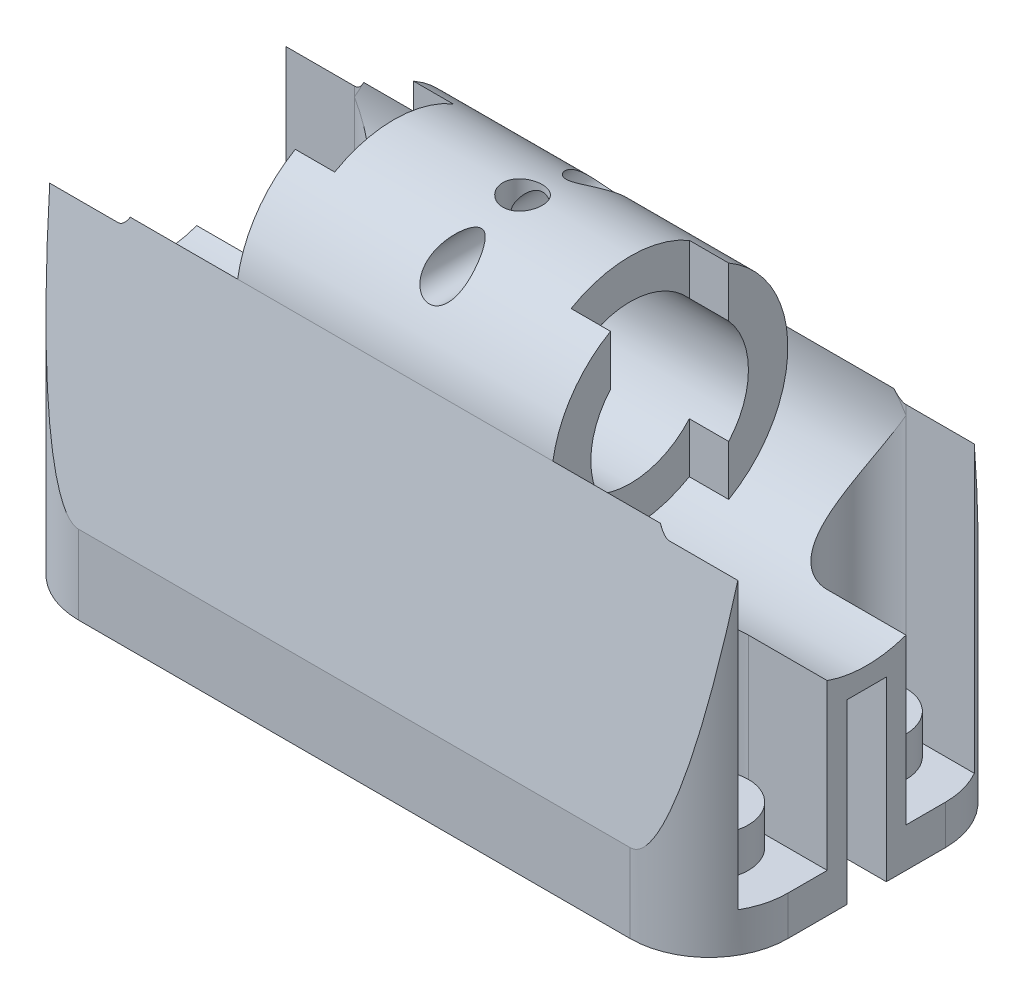
from build123d import *

# Parameters (mm, degrees)
BOSS_EXTRUDE3_DEPTH      = 110
CUT_EXTRUDE3_DEPTH       = 90
CUT_EXTRUDE4_DEPTH       = 10
CUT_EXTRUDE5_DEPTH       = 90
CUT_EXTRUDE6_DEPTH       = 10
CUT_EXTRUDE7_DEPTH       = 10
CUT_EXTRUDE8_DEPTH       = 10
CUT_EXTRUDE11_DEPTH      = 159
CUT_EXTRUDE11_DEPTH_BACK = 165
SKETCH11_R               = 30
CUT_EXTRUDE12_DEPTH      = 165
SKETCH12_R               = 30
CUT_EXTRUDE13_DEPTH      = 165
CUT_EXTRUDE14_DEPTH      = 10
CUT_EXTRUDE15_DEPTH      = 10
SKETCH15_R               = 20
CUT_EXTRUDE16_DEPTH      = 91
SKETCH16_R               = 5
CUT_EXTRUDE17_DEPTH      = 157
SKETCH17_W               = 10
SKETCH17_H               = 45
CUT_EXTRUDE20_DEPTH      = 157
CUT_EXTRUDE20_DEPTH_BACK = 157
SKETCH19_R               = 5
CUT_EXTRUDE23_DEPTH      = 157


with BuildPart() as part:
    # Sketch1 → Boss-Extrude3 (new body)
    with BuildSketch(Plane(origin=(0, 0, 0), x_dir=(1, 0, 0), z_dir=(0, 1, 0))):
        with BuildLine():
            Line((20, 0), (160, 0))
            ThreePointArc((160, 0), (174.142135624, 5.857864376), (180, 20))
            Line((180, 20), (180, 60))
            ThreePointArc((180, 60), (174.142135624, 74.142135624), (160, 80))
            Line((160, 80), (20, 80))
            ThreePointArc((20, 80), (5.857864376, 74.142135624), (0, 60))
            Line((0, 60), (0, 20))
            ThreePointArc((0, 20), (5.857864376, 5.857864376), (20, 0))
        make_face()
    extrude(amount=BOSS_EXTRUDE3_DEPTH)

    # Sketch4 → Cut-Extrude3 (cut)
    with BuildSketch(Plane(origin=(0, 110, 0), x_dir=(1, 0, 0), z_dir=(0, 1, 0))):
        with BuildLine():
            Line((0, 50), (20, 50))
            ThreePointArc((20, 50), (30, 60), (20, 70))
            Line((20, 70), (2.679491924, 70))
            ThreePointArc((2.679491924, 70), (0.681483474, 65.176380902), (0, 60))
            Line((0, 60), (0, 50))
        make_face()
    extrude(amount=-CUT_EXTRUDE3_DEPTH, mode=Mode.SUBTRACT)

    # Sketch5 → Cut-Extrude4 (cut)
    with BuildSketch(Plane(origin=(0, 20, 0), x_dir=(1, 0, 0), z_dir=(0, 1, 0))):
        with BuildLine():
            Line((0, 50), (20, 50))
            ThreePointArc((20, 50), (10, 60), (20, 70))
            Line((20, 70), (2.679491924, 70))
            ThreePointArc((2.679491924, 70), (0.681483474, 65.176380902), (0, 60))
            Line((0, 60), (0, 50))
        make_face()
    extrude(amount=-CUT_EXTRUDE4_DEPTH, mode=Mode.SUBTRACT)

    # Sketch6 → Cut-Extrude5 (cut)
    with BuildSketch(Plane(origin=(0, 110, 0), x_dir=(1, 0, 0), z_dir=(0, 1, 0))):
        with BuildLine():
            Line((2.679491924, 10), (20, 10))
            ThreePointArc((20, 10), (30, 20), (20, 30))
            Line((20, 30), (0, 30))
            Line((0, 30), (0, 20))
            ThreePointArc((0, 20), (0.681483474, 14.823619098), (2.679491924, 10))
        make_face()
        with BuildLine():
            Line((177.320508076, 70), (160, 70))
            ThreePointArc((160, 70), (150, 60), (160, 50))
            Line((160, 50), (180, 50))
            Line((180, 50), (180, 60))
            ThreePointArc((180, 60), (179.318516526, 65.176380902), (177.320508076, 70))
        make_face()
        with BuildLine():
            Line((180, 30), (160, 30))
            ThreePointArc((160, 30), (150, 20), (160, 10))
            Line((160, 10), (177.320508076, 10))
            ThreePointArc((177.320508076, 10), (179.318516526, 14.823619098), (180, 20))
            Line((180, 20), (180, 30))
        make_face()
    extrude(amount=-CUT_EXTRUDE5_DEPTH, mode=Mode.SUBTRACT)

    # Sketch7 → Cut-Extrude6 (cut)
    with BuildSketch(Plane(origin=(0, 20, 0), x_dir=(1, 0, 0), z_dir=(0, 1, 0))):
        with BuildLine():
            Line((2.679491924, 10), (20, 10))
            ThreePointArc((20, 10), (10, 20), (20, 30))
            Line((20, 30), (0, 30))
            Line((0, 30), (0, 20))
            ThreePointArc((0, 20), (0.681483474, 14.823619098), (2.679491924, 10))
        make_face()
    extrude(amount=-CUT_EXTRUDE6_DEPTH, mode=Mode.SUBTRACT)

    # Sketch8 → Cut-Extrude7 (cut)
    with BuildSketch(Plane(origin=(0, 20, 0), x_dir=(1, 0, 0), z_dir=(0, 1, 0))):
        with BuildLine():
            ThreePointArc((170, 60), (167.071067812, 52.928932188), (160, 50))
            Line((160, 50), (180, 50))
            Line((180, 50), (180, 60))
            ThreePointArc((180, 60), (179.318516526, 65.176380902), (177.320508076, 70))
            Line((177.320508076, 70), (160, 70))
            ThreePointArc((160, 70), (167.071067812, 67.071067812), (170, 60))
        make_face()
    extrude(amount=-CUT_EXTRUDE7_DEPTH, mode=Mode.SUBTRACT)

    # Sketch9 → Cut-Extrude8 (cut)
    with BuildSketch(Plane(origin=(0, 20, 0), x_dir=(1, 0, 0), z_dir=(0, 1, 0))):
        with BuildLine():
            Line((180, 30), (160, 30))
            ThreePointArc((160, 30), (167.071067812, 27.071067812), (170, 20))
            ThreePointArc((170, 20), (167.071067812, 12.928932188), (160, 10))
            Line((160, 10), (177.320508076, 10))
            ThreePointArc((177.320508076, 10), (179.318516526, 14.823619098), (180, 20))
            Line((180, 20), (180, 30))
        make_face()
    extrude(amount=-CUT_EXTRUDE8_DEPTH, mode=Mode.SUBTRACT)

    # Sketch10 → Cut-Extrude11 (cut, two sides)
    with BuildSketch(Plane(origin=(50, 0, 0), x_dir=(0, 0, -1), z_dir=(1, 0, 0))) as cut_extrude11_sk:
        with BuildLine():
            Line((69.621902584, 84.747935056), (80, 20))
            Line((80, 20), (80, 110))
            Line((80, 110), (40, 110))
            ThreePointArc((40, 110), (59.46229622, 102.830221765), (69.621902584, 84.747935056))
        make_face()
        with BuildLine():
            ThreePointArc((10.378097416, 84.747935056), (20.53770378, 102.830221765), (40, 110))
            Line((40, 110), (0, 110))
            Line((0, 110), (0, 20))
            Line((0, 20), (10.378097416, 84.747935056))
        make_face()
    extrude(amount=CUT_EXTRUDE11_DEPTH, mode=Mode.SUBTRACT)
    extrude(cut_extrude11_sk.sketch, amount=-CUT_EXTRUDE11_DEPTH_BACK, mode=Mode.SUBTRACT)

    # Sketch11 → Cut-Extrude12 (cut)
    with BuildSketch(Plane(origin=(50, 0, 0), x_dir=(0, 0, -1), z_dir=(1, 0, 0))):
        with Locations((40, 80)):
            Circle(SKETCH11_R)
    extrude(amount=-CUT_EXTRUDE12_DEPTH, mode=Mode.SUBTRACT)

    # Sketch12 → Cut-Extrude13 (cut)
    with BuildSketch(Plane(origin=(130, 0, 0), x_dir=(0, 0, -1), z_dir=(1, 0, 0))):
        with Locations((40, 80)):
            Circle(SKETCH12_R)
    extrude(amount=CUT_EXTRUDE13_DEPTH, mode=Mode.SUBTRACT)

    # Sketch13 → Cut-Extrude14 (cut)
    with BuildSketch(Plane.ZY.offset(-50)):
        with BuildLine():
            Line((-55, 105.980762114), (-55, 54.019237886))
            ThreePointArc((-55, 54.019237886), (-40, 50), (-25, 54.019237886))
            Line((-25, 54.019237886), (-25, 105.980762114))
            ThreePointArc((-25, 105.980762114), (-40, 110), (-55, 105.980762114))
        make_face()
    extrude(amount=-CUT_EXTRUDE14_DEPTH, mode=Mode.SUBTRACT)

    # Sketch14 → Cut-Extrude15 (cut)
    with BuildSketch(Plane(origin=(130, 0, 0), x_dir=(0, 0, -1), z_dir=(1, 0, 0))):
        with BuildLine():
            ThreePointArc((25, 105.980762114), (40, 110), (55, 105.980762114))
            Line((55, 105.980762114), (55, 54.019237886))
            ThreePointArc((55, 54.019237886), (40, 50), (25, 54.019237886))
            Line((25, 54.019237886), (25, 105.980762114))
        make_face()
    extrude(amount=-CUT_EXTRUDE15_DEPTH, mode=Mode.SUBTRACT)

    # Sketch15 → Cut-Extrude16 (cut)
    with BuildSketch(Plane.ZY.offset(-50)):
        with Locations((-40, 80)):
            Circle(SKETCH15_R)
    extrude(amount=-CUT_EXTRUDE16_DEPTH, mode=Mode.SUBTRACT)

    # Sketch16 → Cut-Extrude17 (cut)
    with BuildSketch(Plane.XZ):
        with Locations((92.679491924, -40)):
            Circle(SKETCH16_R)
    extrude(amount=-CUT_EXTRUDE17_DEPTH, mode=Mode.SUBTRACT)

    # Sketch17 → Cut-Extrude20 (cut, two sides)
    with BuildSketch(Plane(origin=(130, 0, 0), x_dir=(0, 0, -1), z_dir=(1, 0, 0))) as cut_extrude20_sk:
        with Locations((40, 22.5)):
            Rectangle(SKETCH17_W, SKETCH17_H)
    extrude(amount=CUT_EXTRUDE20_DEPTH, mode=Mode.SUBTRACT)
    extrude(cut_extrude20_sk.sketch, amount=-CUT_EXTRUDE20_DEPTH_BACK, mode=Mode.SUBTRACT)

    # Sketch19 → Cut-Extrude23 (cut)
    with BuildSketch(Plane.XY):
        with Locations((93, 103)):
            Circle(SKETCH19_R)
    extrude(amount=-CUT_EXTRUDE23_DEPTH, mode=Mode.SUBTRACT)


solid = part.part
